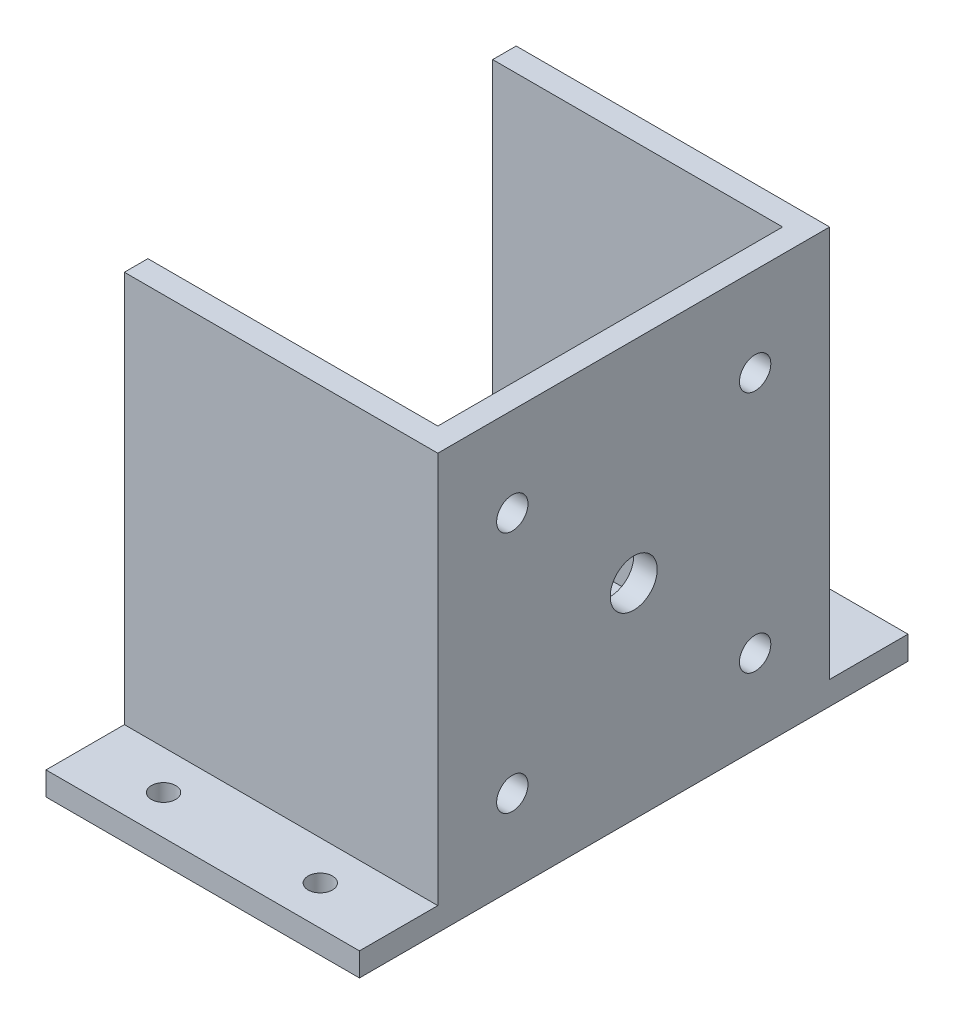
from build123d import *

# Parameters (mm, degrees)
SKETCH1_W           = 40
SKETCH1_H           = 70
SKETCH1_R           = 1.55
BOSS_EXTRUDE1_DEPTH = 3
SKETCH2_W           = 3
SKETCH2_H           = 44
BOSS_EXTRUDE2_DEPTH = 50
SKETCH3_R           = 3
SKETCH3_R_2         = 2
CUT_EXTRUDE1_DEPTH  = 44


with BuildPart() as part:
    # Sketch1 → Boss-Extrude1 (new body)
    with BuildSketch(Plane(origin=(0, 0, 0), x_dir=(1, 0, 0), z_dir=(0, 1, 0))):
        with Locations((20, 35)):
            Rectangle(SKETCH1_W, SKETCH1_H)
        with Locations((10, 5)):
            Circle(SKETCH1_R, mode=Mode.SUBTRACT)
        with Locations((30, 5)):
            Circle(SKETCH1_R, mode=Mode.SUBTRACT)
        with Locations((30, 65)):
            Circle(SKETCH1_R, mode=Mode.SUBTRACT)
        with Locations((10, 65)):
            Circle(SKETCH1_R, mode=Mode.SUBTRACT)
    extrude(amount=BOSS_EXTRUDE1_DEPTH)

    # Sketch2 → Boss-Extrude2 (add)
    with BuildSketch(Plane(origin=(0, 3, 0), x_dir=(1, 0, 0), z_dir=(0, 1, 0))):
        Polygon((0, 60), (0, 57), (37, 57), (40, 57), (40, 60), align=None)
        with Locations((38.5, 35)):
            Rectangle(SKETCH2_W, SKETCH2_H)
        Polygon((37, 13), (0, 13), (0, 10), (40, 10), (40, 13), align=None)
    extrude(amount=BOSS_EXTRUDE2_DEPTH)

    # Sketch3 → Cut-Extrude1 (cut)
    with BuildSketch(Plane(origin=(40, 0, 0), x_dir=(0, 0, -1), z_dir=(1, 0, 0))):
        with Locations((35, 26.15)):
            Circle(SKETCH3_R)
        with Locations((19.505, 41.645)):
            Circle(SKETCH3_R_2)
        with Locations((50.495, 41.645)):
            Circle(SKETCH3_R_2)
        with Locations((50.495, 10.655)):
            Circle(SKETCH3_R_2)
        with Locations((19.505, 10.655)):
            Circle(SKETCH3_R_2)
    extrude(amount=-CUT_EXTRUDE1_DEPTH, mode=Mode.SUBTRACT)


solid = part.part
